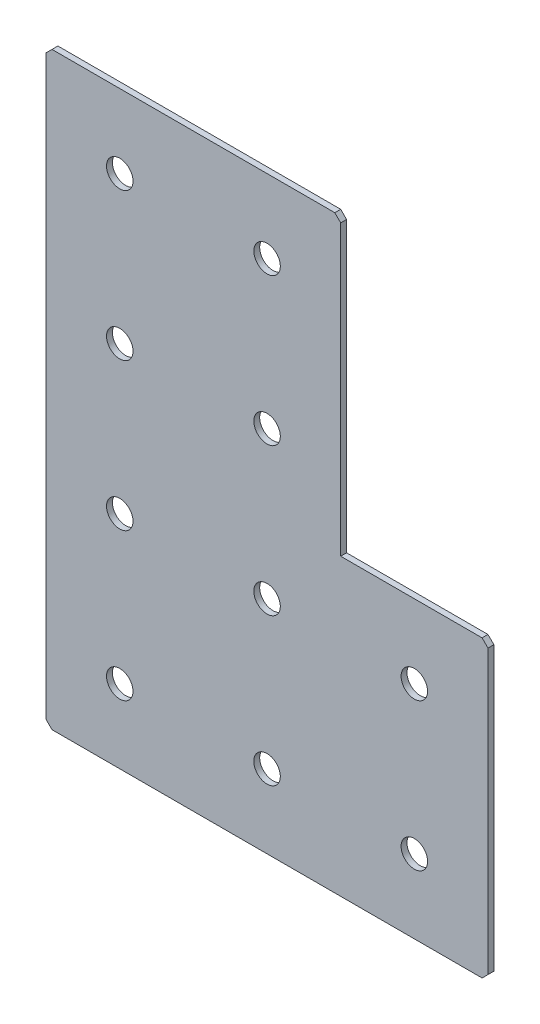
from build123d import *

# Parameters (mm, degrees)
EXTRUDE_1_DEPTH   = 2
HOLE_WIZARD_M81_D = 9
CHAMFER_1_SIZE    = 2


with BuildPart() as part:
    # Эскиз1 → Бобышка-Вытянуть1 (new body)
    with BuildSketch(Plane(origin=(0, 0, 0), x_dir=(1, 0, 0), z_dir=(0, 0, -1))):
        Polygon((0, 0), (0, 200), (150, 200), (150, 100), (100, 100), (100, 0), align=None)
    extrude(amount=EXTRUDE_1_DEPTH)

    # Отверстие с зазором M81 (through all)
    with Locations(Plane(origin=(0, 0, -2), x_dir=(1, 0, 0), z_dir=(0, 0, -1))):
        with Locations((25, 175), (25, 125), (25, 75), (25, 25), (75, 175), (75, 125), (75, 75), (75, 25), (125, 175), (125, 125)):
            Hole(HOLE_WIZARD_M81_D / 2)

    # Фаска1
    chamfer_1_edges = [part.edges().sort_by_distance(p)[0] for p in [
        (0, 0, -1),
        (0, -200, -1),
        (150, -200, -1),
        (150, -100, -1),
        (100, 0, -1),
    ]]
    chamfer(chamfer_1_edges, length=CHAMFER_1_SIZE)


solid = part.part
